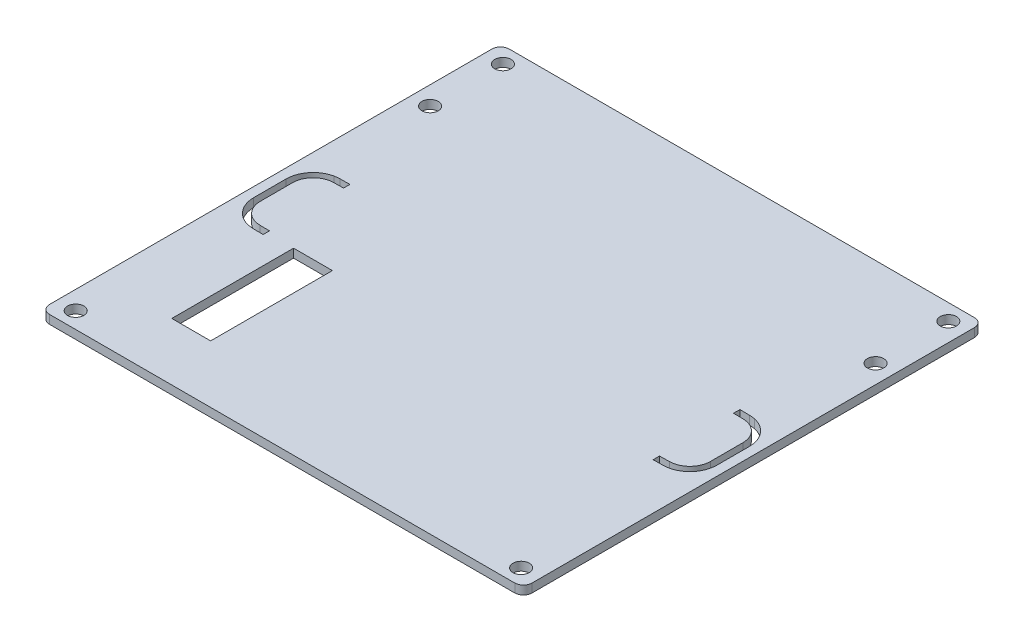
from build123d import *

# Parameters (mm, degrees)
SKETCH1_R           = 3
SKETCH1_W           = 14.2494
SKETCH1_H           = 44.671382498
BOSS_EXTRUDE1_DEPTH = 3.175
FILLET1_R           = 3.175


with BuildPart() as part:
    # Sketch1 → Boss-Extrude1 (new body)
    with BuildSketch(Plane(origin=(0, 0, 0), x_dir=(1, 0, 0), z_dir=(0, 1, 0))):
        Polygon((16.960672162, 168.629876359), (160.039327838, 168.629876359), (177, 168.629876359), (177, 0), (160.039327838, 0), (16.960672162, 0), (0, 0), (0, 168.629876359), align=None)
        with Locations((6.800672162, 162.669204197)):
            Circle(SKETCH1_R, mode=Mode.SUBTRACT)
        with Locations((6.800672162, 135.969204197)):
            Circle(SKETCH1_R, mode=Mode.SUBTRACT)
        with Locations((170.199327838, 162.669204197)):
            Circle(SKETCH1_R, mode=Mode.SUBTRACT)
        with Locations((170.199327838, 135.969204197)):
            Circle(SKETCH1_R, mode=Mode.SUBTRACT)
        with Locations((6.800672162, 5.96493818)):
            Circle(SKETCH1_R, mode=Mode.SUBTRACT)
        with Locations((170.199327838, 5.96493818)):
            Circle(SKETCH1_R, mode=Mode.SUBTRACT)
        with Locations((34, 43.470295491)):
            Rectangle(SKETCH1_W, SKETCH1_H, mode=Mode.SUBTRACT)
        with BuildLine():
            Line((16.951048024, 64.540050733), (16.991793389, 66.874351095))
            Line((16.991793389, 66.874351095), (13.367278288, 66.937617241))
            ThreePointArc((13.367278288, 66.937617241), (8.075887225, 69.210978252), (5.895219965, 74.541239031))
            Line((5.895219965, 74.541239031), (5.895219965, 86.398551951))
            ThreePointArc((5.895219965, 86.398551951), (8.075887225, 91.72881273), (13.367278288, 94.00217374))
            Line((13.367278288, 94.00217374), (16.987373531, 94.065362738))
            Line((16.987373531, 94.065362738), (16.946445409, 96.410133308))
            Line((16.946445409, 96.410133308), (13.326350165, 96.34694431))
            ThreePointArc((13.326350165, 96.34694431), (12.377781101, 96.284971401), (11.439455037, 96.132760663))
            Line((11.439455037, 96.132760663), (11.375913148, 96.152499099))
            ThreePointArc((11.375913148, 96.152499099), (5.72648647, 92.661436057), (3.517453736, 86.398551951))
            Line((3.517453736, 86.398551951), (3.517453736, 74.541239031))
            ThreePointArc((3.517453736, 74.541239031), (5.726486031, 68.278355625), (11.375911736, 64.787292544))
            Line((11.375911736, 64.787292544), (11.459759836, 64.8134536))
            ThreePointArc((11.459759836, 64.8134536), (12.38817048, 64.664183621), (13.326532399, 64.603316889))
            Line((13.326532399, 64.603316889), (16.951048024, 64.540050733))
        make_face(mode=Mode.SUBTRACT)
        with BuildLine():
            Line((160.012549311, 66.878848625), (160.053371832, 64.540127941))
            Line((160.053371832, 64.540127941), (163.673466588, 64.60331693))
            ThreePointArc((163.673466588, 64.60331693), (164.611836733, 64.664184588), (165.540255354, 64.81345704))
            Line((165.540255354, 64.81345704), (165.624086371, 64.787291495))
            ThreePointArc((165.624086371, 64.787291495), (171.273513049, 68.278354537), (173.482545784, 74.541238643))
            Line((173.482545784, 74.541238643), (173.482545784, 86.398551563))
            ThreePointArc((173.482545784, 86.398551563), (171.273513446, 92.661435036), (165.624087648, 96.152498114))
            Line((165.624087648, 96.152498114), (165.560531376, 96.132763539))
            ThreePointArc((165.560531376, 96.132763539), (164.622211999, 96.284972184), (163.673649835, 96.34694431))
            Line((163.673649835, 96.34694431), (160.04913421, 96.410210466))
            Line((160.04913421, 96.410210466), (160.008128929, 94.061019514))
            Line((160.008128929, 94.061019514), (163.632644554, 93.997753359))
            ThreePointArc((163.632644554, 93.997753359), (168.920959456, 91.725713971), (171.10035898, 86.398551951))
            Line((171.10035898, 86.398551951), (171.10035898, 74.541239031))
            ThreePointArc((171.10035898, 74.541239031), (168.920959456, 69.21407701), (163.632644554, 66.942037623))
            Line((163.632644554, 66.942037623), (160.012549311, 66.878848625))
        make_face(mode=Mode.SUBTRACT)
    extrude(amount=BOSS_EXTRUDE1_DEPTH)

    # Fillet1
    fillet1_edges = [part.edges().sort_by_distance(p)[0] for p in [
        (0, 1.5875, 0),
        (0, 1.5875, -168.629876359),
        (177, 1.5875, -168.629876359),
        (177, 1.5875, 0),
    ]]
    fillet(fillet1_edges, radius=FILLET1_R)


solid = part.part
